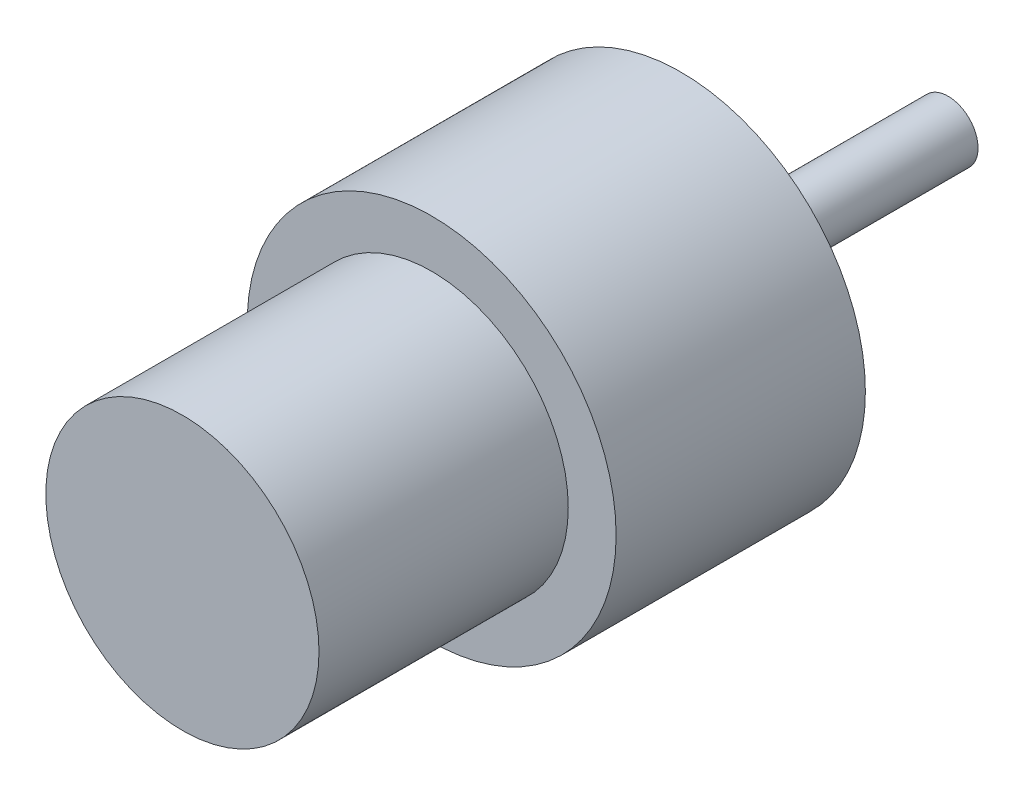
from build123d import *

# Parameters (mm, degrees)
SKETCH1_R           = 18.5
BOSS_EXTRUDE1_DEPTH = 25
SKETCH2_R           = 6
BOSS_EXTRUDE2_DEPTH = 6.8
SKETCH3_R           = 3
BOSS_EXTRUDE3_DEPTH = 20
SKETCH5_R           = 13.7
BOSS_EXTRUDE4_DEPTH = 25


with BuildPart() as part:
    # Sketch1 → Boss-Extrude1 (new body)
    with BuildSketch(Plane.XY):
        Circle(SKETCH1_R)
    extrude(amount=BOSS_EXTRUDE1_DEPTH)

    # Sketch2 → Boss-Extrude2 (add)
    with BuildSketch(Plane(origin=(0, 0, 0), x_dir=(-1, 0, 0), z_dir=(0, 0, -1))):
        Circle(SKETCH2_R)
    extrude(amount=BOSS_EXTRUDE2_DEPTH)

    # Sketch3 → Boss-Extrude3 (add)
    with BuildSketch(Plane(origin=(0, 0, -6.8), x_dir=(-1, 0, 0), z_dir=(0, 0, -1))):
        Circle(SKETCH3_R)
    extrude(amount=BOSS_EXTRUDE3_DEPTH)

    # Sketch5 → Boss-Extrude4 (add)
    with BuildSketch(Plane.XY.offset(25)):
        Circle(SKETCH5_R)
    extrude(amount=BOSS_EXTRUDE4_DEPTH)


solid = part.part
